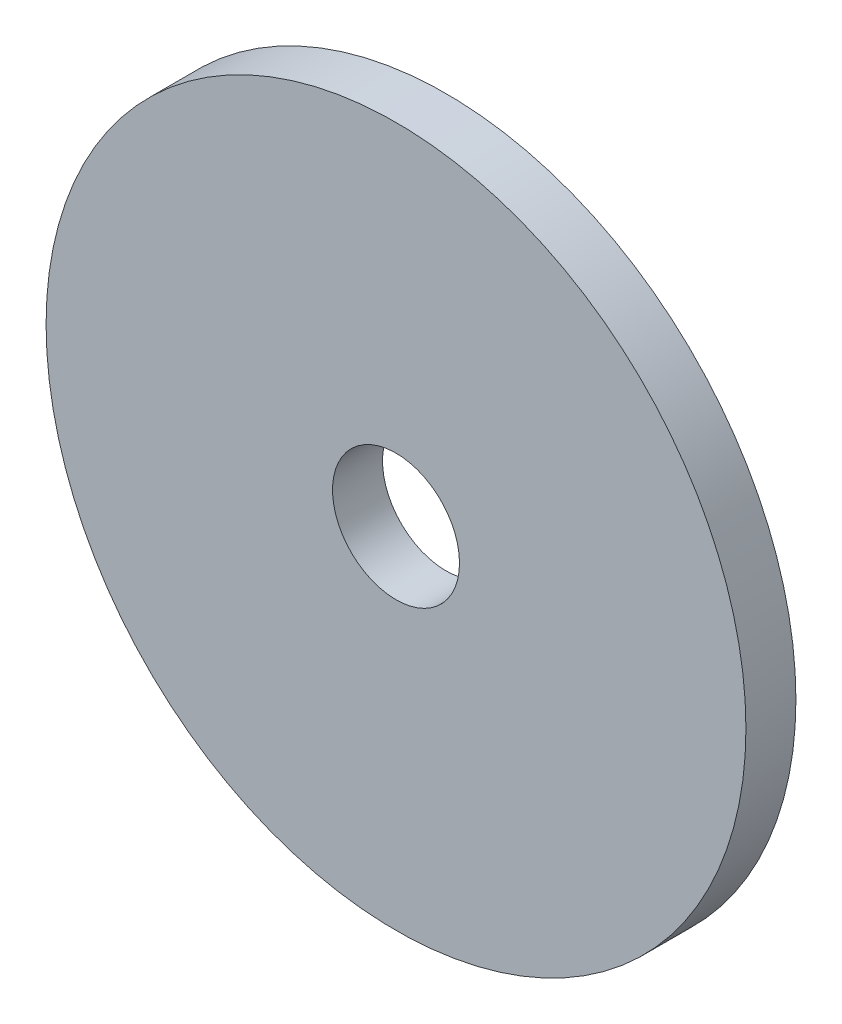
from build123d import *

# Parameters (mm, degrees)
SKETCH1_R           = 140
SKETCH1_R_2         = 25.4
BOSS_EXTRUDE1_DEPTH = 20


with BuildPart() as part:
    # Sketch1 → Boss-Extrude1 (new body)
    with BuildSketch(Plane.XY):
        Circle(SKETCH1_R)
        Circle(SKETCH1_R_2, mode=Mode.SUBTRACT)
    extrude(amount=BOSS_EXTRUDE1_DEPTH)


solid = part.part
